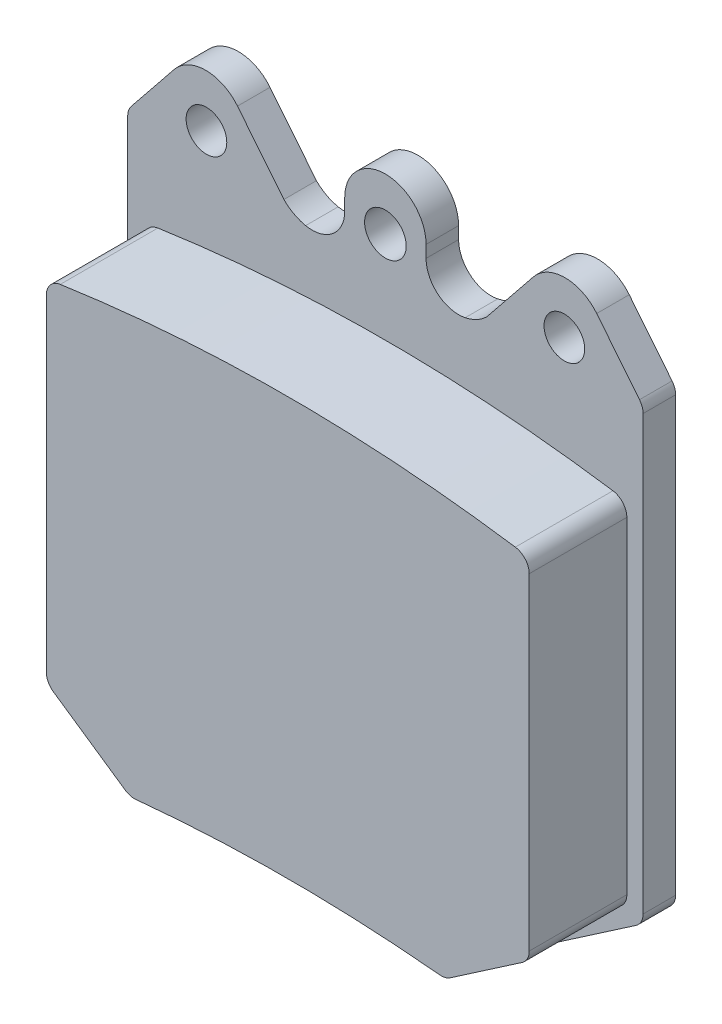
from build123d import *

# Parameters (mm, degrees)
SKETCH1_W           = 50.292
SKETCH1_H           = 57.15
BOSS_EXTRUDE1_DEPTH = 3.175
SKETCH3_R           = 2.032
SKETCH3_R_2         = 1.984375
CUT_EXTRUDE1_DEPTH  = 4.175
CUT_EXTRUDE2_DEPTH  = 4.175
FILLET1_R           = 1.5875
BOSS_EXTRUDE2_DEPTH = 9.525


with BuildPart() as part:
    # Sketch1 → Boss-Extrude1 (new body)
    with BuildSketch(Plane.XY):
        with Locations((25.146, -28.575)):
            Rectangle(SKETCH1_W, SKETCH1_H)
    extrude(amount=BOSS_EXTRUDE1_DEPTH)

    # Sketch3 → Cut-Extrude1 (cut, through all)
    with BuildSketch(Plane.XY.offset(3.175)):
        with Locations((25.146, -5.08)):
            Circle(SKETCH3_R)
        with Locations((42.6085, -5.08)):
            Circle(SKETCH3_R_2)
        with Locations((7.6835, -5.08)):
            Circle(SKETCH3_R_2)
        Polygon((0, -57.15), (9.271, -57.15), (0, -50.8), align=None)
        Polygon((50.292, -50.8), (41.021, -57.15), (50.292, -57.15), align=None)
    extrude(amount=-CUT_EXTRUDE1_DEPTH, mode=Mode.SUBTRACT)

    # Sketch4 → Cut-Extrude2 (cut, through all)
    with BuildSketch(Plane.XY.offset(3.175)):
        with BuildLine():
            Line((21.17725, -5.145617642), (21.17725, -3.96875))
            ThreePointArc((21.17725, -3.96875), (22.339669962, -1.162419962), (25.146, 0))
            Line((25.146, 0), (7.62, 0))
            ThreePointArc((7.62, 0), (9.334782633, -0.389574524), (10.71291739, -1.481816429))
            Line((10.71291739, -1.481816429), (15.24, -7.112))
            ThreePointArc((15.24, -7.112), (16.21713524, -7.8392426), (17.36190992, -8.2553748))
            ThreePointArc((17.36190992, -8.2553748), (20.008184352, -7.606684967), (21.17725, -5.145617642))
        make_face()
        with BuildLine():
            Line((42.672, 0), (25.146, 0))
            ThreePointArc((25.146, 0), (27.952330038, -1.162419962), (29.11475, -3.96875))
            Line((29.11475, -3.96875), (29.11475, -5.145617642))
            ThreePointArc((29.11475, -5.145617642), (30.283815648, -7.606684967), (32.93009008, -8.2553748))
            ThreePointArc((32.93009008, -8.2553748), (34.07486476, -7.8392426), (35.052, -7.112))
            Line((35.052, -7.112), (39.57908261, -1.481816429))
            ThreePointArc((39.57908261, -1.481816429), (40.957217367, -0.389574524), (42.672, 0))
        make_face()
        with BuildLine():
            Line((50.292, 0), (42.672, 0))
            ThreePointArc((42.672, 0), (44.386782633, -0.389574524), (45.76491739, -1.481816429))
            Line((45.76491739, -1.481816429), (50.292, -7.112))
            Line((50.292, -7.112), (50.292, 0))
        make_face()
        with BuildLine():
            ThreePointArc((4.52708261, -1.481816429), (5.905217367, -0.389574524), (7.62, 0))
            Line((7.62, 0), (0, 0))
            Line((0, 0), (0, -7.112))
            Line((0, -7.112), (4.52708261, -1.481816429))
        make_face()
    extrude(amount=-CUT_EXTRUDE2_DEPTH, mode=Mode.SUBTRACT)

    # Fillet1
    fillet1_edges = [part.edges().sort_by_distance(p)[0] for p in [
        (0, -7.112, 1.5875),
        (0, -50.8, 1.5875),
        (9.271, -57.15, 1.5875),
        (41.021, -57.15, 1.5875),
        (50.292, -50.8, 1.5875),
        (50.292, -7.112, 1.5875),
    ]]
    fillet(fillet1_edges, radius=FILLET1_R)

    # Sketch6 → Boss-Extrude2 (add)
    with BuildSketch(Plane.XY.offset(3.175)):
        with BuildLine():
            Line((1.5875, -17.239611386), (1.5875, -49.126312385))
            ThreePointArc((1.5875, -49.126312385), (1.770672966, -49.86659735), (2.277921203, -50.436047428))
            Line((2.277921203, -50.436047428), (9.284630112, -55.235163118))
            ThreePointArc((9.284630112, -55.235163118), (9.786487736, -55.462944408), (10.33597995, -55.505414371))
            ThreePointArc((10.33597995, -55.505414371), (25.146, -54.784098787), (39.95602005, -55.505414371))
            ThreePointArc((39.95602005, -55.505414371), (40.505512264, -55.462944408), (41.007369888, -55.235163118))
            Line((41.007369888, -55.235163118), (48.014078797, -50.436047428))
            ThreePointArc((48.014078797, -50.436047428), (48.521327034, -49.86659735), (48.7045, -49.126312385))
            Line((48.7045, -49.126312385), (48.7045, -17.239611386))
            ThreePointArc((48.7045, -17.239611386), (48.318520542, -16.202063972), (47.348273684, -15.669048197))
            ThreePointArc((47.348273684, -15.669048197), (25.146, -14.043114413), (2.943726316, -15.669048197))
            ThreePointArc((2.943726316, -15.669048197), (1.973479458, -16.202063972), (1.5875, -17.239611386))
        make_face()
    extrude(amount=BOSS_EXTRUDE2_DEPTH)


solid = part.part
